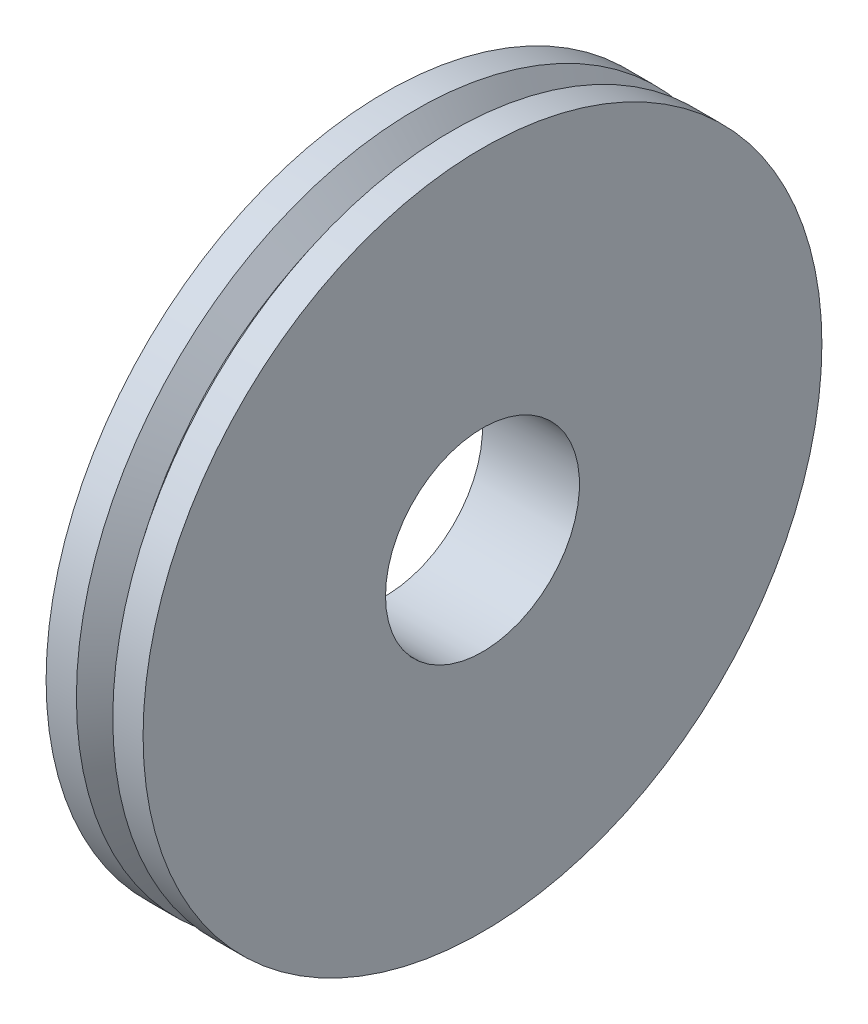
from build123d import *


with BuildPart() as part:
    # 草图1 → 旋转1 (revolve)
    with BuildSketch(Plane.XY):
        Polygon((-5.065536665, 4), (-5.065536665, 14), (-3.815536665, 14), (-3.065536665, 13), (-2.315536665, 14), (-1.065536665, 14), (-1.065536665, 4), align=None)
    revolve(axis=Axis((-33.4645, 0, 0), (1, 0, 0)))


solid = part.part
